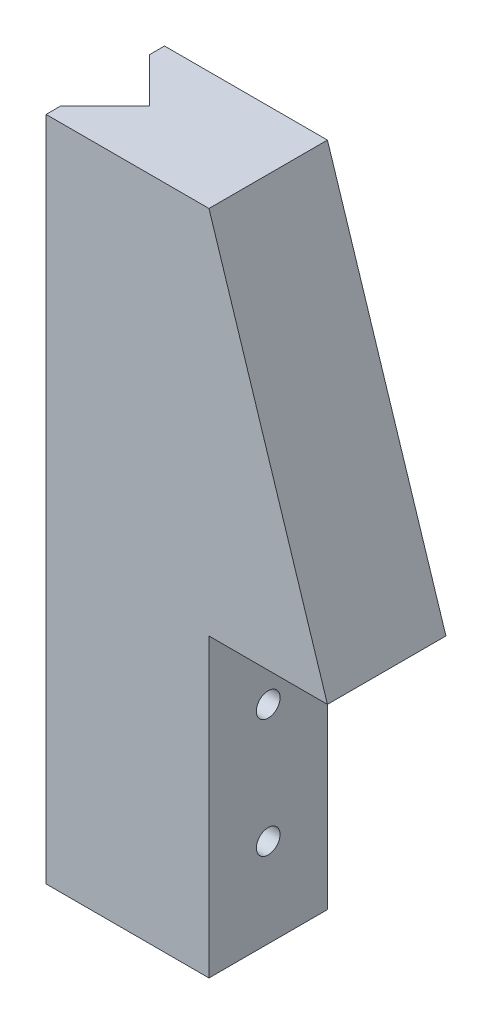
from build123d import *

# Parameters (mm, degrees)
BOSS_EXTRUDE1_DEPTH       = 8
CUT_EXTRUDE1_DEPTH        = 46
M2X0_4_TAPPED_HOLE1_D     = 1.6
M2X0_4_TAPPED_HOLE1_DEPTH = 5
M2X0_4_TAPPED_HOLE1_TIP   = 0.480688495


with BuildPart() as part:
    # Sketch1 → Boss-Extrude1 (new body)
    with BuildSketch(Plane.XY):
        Polygon((0, 0), (-8, 0), (-8, -20), (-19, -20), (-19, 25), (-8, 25), align=None)
    extrude(amount=BOSS_EXTRUDE1_DEPTH)

    # Sketch2 → Cut-Extrude1 (cut, through all)
    with BuildSketch(Plane(origin=(0, 25, 0), x_dir=(1, 0, 0), z_dir=(0, 1, 0))):
        Polygon((-19, -4), (-19, -1), (-16, -4), (-19, -7), align=None)
    extrude(amount=-CUT_EXTRUDE1_DEPTH, mode=Mode.SUBTRACT)

    # M2x0.4 Tapped Hole1
    with Locations(Plane(origin=(-8, -6, 4), x_dir=(0, 0, 1), z_dir=(1, 0, 0))):
        with Locations((0, 0), (0, 8)):
            Hole(M2X0_4_TAPPED_HOLE1_D / 2, depth=M2X0_4_TAPPED_HOLE1_DEPTH)
            with Locations((0, 0, -(M2X0_4_TAPPED_HOLE1_DEPTH + M2X0_4_TAPPED_HOLE1_TIP / 2))):  # 118° drill point
                Cone(0, M2X0_4_TAPPED_HOLE1_D / 2, M2X0_4_TAPPED_HOLE1_TIP, mode=Mode.SUBTRACT)


solid = part.part
